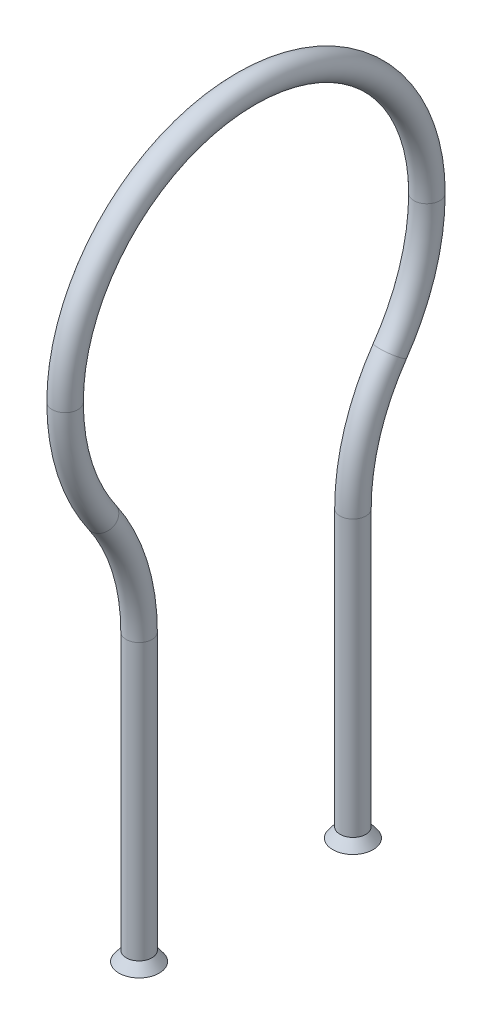
from build123d import *

# Parameters (mm, degrees)
SKETCH8_R           = 2.38125
SKETCH8_R_2         = 1.82245
SKETCH10_R          = 2.38125
BOSS_EXTRUDE3_DEPTH = 1.778
BOSS_EXTRUDE3_TAPER = -37
SKETCH11_R          = 1.82245
CUT_EXTRUDE2_DEPTH  = 2.7780001
CUT_EXTRUDE2_TAPER  = -37


with BuildPart() as part:
    # Sweep2: sweep along a path in Sketch9
    with BuildLine(Plane(origin=(0, 0, 0), x_dir=(0, 0, -1), z_dir=(1, 0, 0))) as sweep2_path:
        Line((-19.702223994, -127.635721936), (-19.702223994, -76.835721936))
        ThreePointArc((-19.702223994, -76.835721936), (-21.446564241, -65.439406568), (-26.519861997, -55.086610968))
        ThreePointArc((-26.519861997, -55.086610968), (-31.593159753, -44.733815368), (-33.3375, -33.3375))
        ThreePointArc((-33.3375, -33.3375), (-23.573172318, -9.764327682), (0, 0))
    # Sketch8 → Sweep2 (sweep)
    with BuildSketch(Plane.XY):
        Circle(SKETCH8_R)
        Circle(SKETCH8_R_2, mode=Mode.SUBTRACT)
    sweep2 = sweep(path=sweep2_path.line)

    # Sketch10 → Boss-Extrude3 (add)
    with BuildSketch(Plane.XZ.offset(127.635721936)):
        with Locations(Location((0, 19.702223994, 0), (0, 0, 270))):  # turned: the seam where the file's is
            Circle(SKETCH10_R)
    boss_extrude3 = extrude(amount=BOSS_EXTRUDE3_DEPTH, taper=BOSS_EXTRUDE3_TAPER)

    # Sketch11 → Cut-Extrude2 (cut, through all)
    with BuildSketch(Plane(origin=(0, -127.635721936, 0), x_dir=(1, 0, 0), z_dir=(0, 1, 0))):
        with Locations(Location((0, -19.702223994, 0), (0, 0, 90))):  # turned: the seam where the file's is
            Circle(SKETCH11_R)
    cut_extrude2 = extrude(amount=-CUT_EXTRUDE2_DEPTH, taper=CUT_EXTRUDE2_TAPER, mode=Mode.SUBTRACT)

    # Mirror1: Sweep2, Boss-Extrude3, Cut-Extrude2 across plane
    add(sweep2.mirror(Plane.XY))
    add(boss_extrude3.mirror(Plane.XY))
    add(cut_extrude2.mirror(Plane.XY), mode=Mode.SUBTRACT)


solid = part.part
